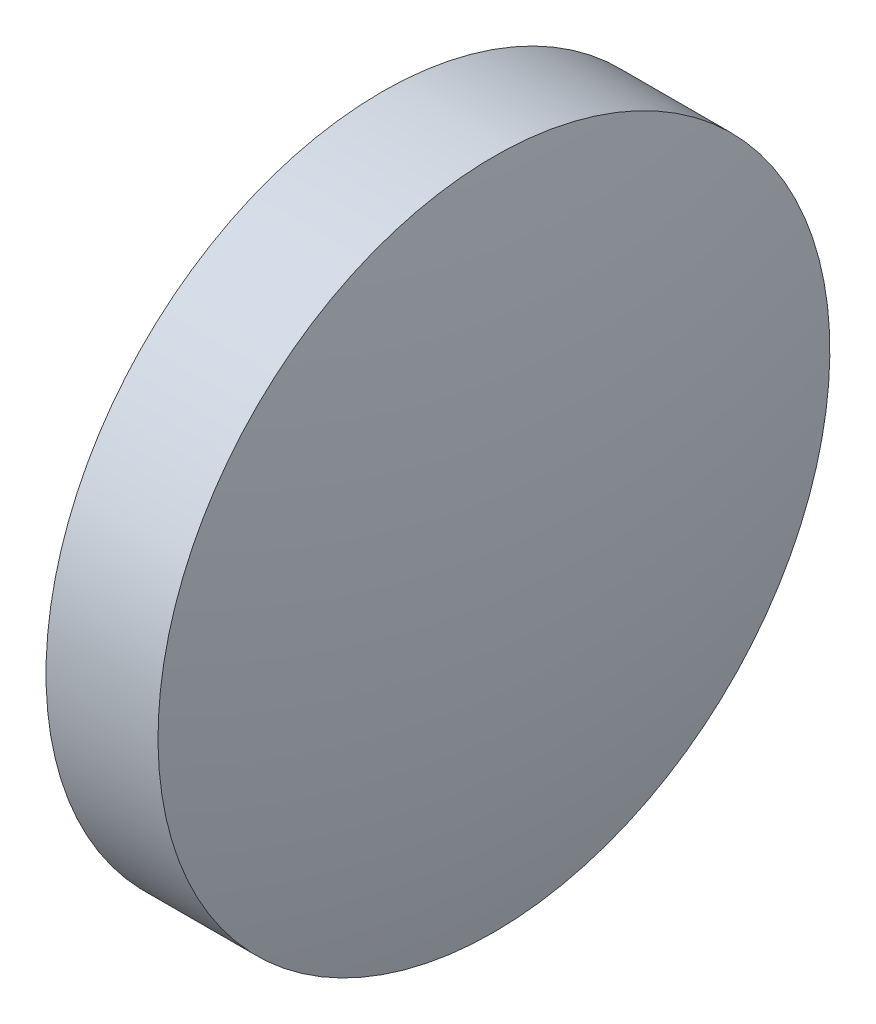
from build123d import *

# Parameters (mm, degrees)
SKETCH_1_ONE_SIDE_W = 0.999999428
SKETCH_1_ONE_SIDE_H = 3


with BuildPart() as part:
    # 草图1 one side → 旋转1 (revolve)
    with BuildSketch(Plane.XY, mode=Mode.PRIVATE) as revolve_1_sk:
        with Locations((20.42319538, 12.984121187)):
            Rectangle(SKETCH_1_ONE_SIDE_W, SKETCH_1_ONE_SIDE_H)
        with BuildLine():
            Line((19.608200037, 11.484121187), (19.923195666, 11.484121187))
            Line((19.923195666, 11.484121187), (19.923195666, 14.484121187))
            ThreePointArc((19.923195666, 14.484121187), (19.687164802, 12.992367042), (19.608200037, 11.484121187))
        make_face()
        with BuildLine():
            Line((20.923195094, 11.484121187), (21.238190723, 11.484121187))
            ThreePointArc((21.238190723, 11.484121187), (21.159225958, 12.992367042), (20.923195094, 14.484121187))
            Line((20.923195094, 14.484121187), (20.923195094, 11.484121187))
        make_face()
    revolve(revolve_1_sk.sketch.rotate(Axis((19.322373688, 11.484121187, 0), (1, 0, 0)), 180), axis=Axis((19.322373688, 11.484121187, 0), (1, 0, 0)))  # turned: the seam where the file's is


solid = part.part
